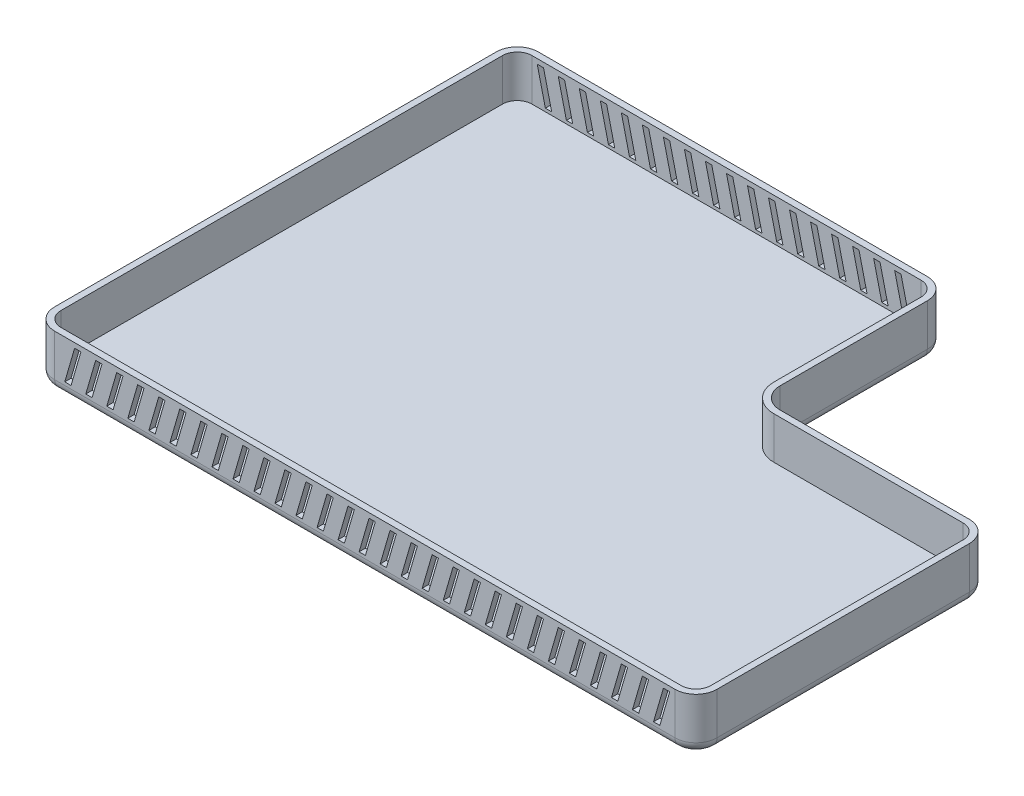
from build123d import *

# Parameters (mm, degrees)
BOSS_EXTRUDE1_DEPTH = 5
BOSS_EXTRUDE2_DEPTH = 25
FILLET1_R           = 5
CUT_EXTRUDE1_DEPTH  = 10
LPATTERN1_COUNT     = 29
LPATTERN1_PITCH     = 10
CUT_EXTRUDE2_DEPTH  = 10
LPATTERN2_COUNT     = 18
LPATTERN2_PITCH     = 10


with BuildPart() as part:
    # Sketch1 → Boss-Extrude1 (new body)
    with BuildSketch(Plane(origin=(0, 0, 0), x_dir=(1, 0, 0), z_dir=(0, 1, 0))):
        with BuildLine():
            Line((305, 140), (215, 140))
            ThreePointArc((215, 140), (207.928932188, 142.928932188), (205, 150))
            Line((205, 150), (205, 220))
            ThreePointArc((205, 220), (202.071067812, 227.071067812), (195, 230))
            Line((195, 230), (10, 230))
            ThreePointArc((10, 230), (2.928932188, 227.071067812), (0, 220))
            Line((0, 220), (0, 10))
            ThreePointArc((0, 10), (2.928932188, 2.928932188), (10, 0))
            Line((10, 0), (305, 0))
            ThreePointArc((305, 0), (312.071067812, 2.928932188), (315, 10))
            Line((315, 10), (315, 130))
            ThreePointArc((315, 130), (312.071067812, 137.071067812), (305, 140))
        make_face()
    extrude(amount=BOSS_EXTRUDE1_DEPTH)

    # Sketch3 → Boss-Extrude2 (add)
    with BuildSketch(Plane(origin=(0, 0, 0), x_dir=(1, 0, 0), z_dir=(0, 1, 0))):
        with BuildLine():
            Line((10, 0), (305, 0))
            ThreePointArc((305, 0), (312.071067812, 2.928932188), (315, 10))
            Line((315, 10), (315, 130))
            ThreePointArc((315, 130), (312.071067812, 137.071067812), (305, 140))
            Line((305, 140), (215, 140))
            ThreePointArc((215, 140), (207.928932188, 142.928932188), (205, 150))
            Line((205, 150), (205, 220))
            ThreePointArc((205, 220), (202.071067812, 227.071067812), (195, 230))
            Line((195, 230), (10, 230))
            ThreePointArc((10, 230), (2.928932188, 227.071067812), (0, 220))
            Line((0, 220), (0, 10))
            ThreePointArc((0, 10), (2.928932188, 2.928932188), (10, 0))
        make_face()
        with BuildLine():
            Line((10, 3), (305, 3))
            ThreePointArc((305, 3), (309.949747468, 5.050252532), (312, 10))
            Line((312, 10), (312, 130))
            ThreePointArc((312, 130), (309.949747468, 134.949747468), (305, 137))
            Line((305, 137), (215, 137))
            ThreePointArc((215, 137), (205.807611845, 140.807611845), (202, 150))
            Line((202, 150), (202, 220))
            ThreePointArc((202, 220), (199.949747468, 224.949747468), (195, 227))
            Line((195, 227), (10, 227))
            ThreePointArc((10, 227), (5.050252532, 224.949747468), (3, 220))
            Line((3, 220), (3, 10))
            ThreePointArc((3, 10), (5.050252532, 5.050252532), (10, 3))
        make_face(mode=Mode.SUBTRACT)
    extrude(amount=BOSS_EXTRUDE2_DEPTH)

    # Fillet1
    fillet1_edges = [part.edges().sort_by_distance(p)[0] for p in [
        (0, 0, -115),
        (2.928932188, 0, -227.071067812),
        (102.5, 0, -230),
        (202.071067812, 0, -227.071067812),
        (205, 0, -185),
        (207.928932188, 0, -142.928932188),
        (260, 0, -140),
        (312.071067812, 0, -137.071067812),
        (315, 0, -70),
        (312.071067812, 0, -2.928932188),
        (157.5, 0, 0),
        (2.928932188, 0, -2.928932188),
    ]]
    fillet(fillet1_edges, radius=FILLET1_R)

    # Sketch4 → Cut-Extrude1 (cut)
    with BuildSketch(Plane.XY):
        Polygon((297.799187642, 6.5), (294.799187642, 6.5), (299.5, 22.700711027), (302.5, 22.700711027), align=None)
    cut_extrude1 = extrude(amount=-CUT_EXTRUDE1_DEPTH, mode=Mode.SUBTRACT)

    # LPattern1: Cut-Extrude1 ×29
    with Locations(*[(-i * LPATTERN1_PITCH, 0, 0) for i in range(1, LPATTERN1_COUNT)]):
        add(cut_extrude1, mode=Mode.SUBTRACT)

    # Sketch5 → Cut-Extrude2 (cut)
    with BuildSketch(Plane(origin=(0, 0, -230), x_dir=(-1, 0, 0), z_dir=(0, 0, -1))):
        Polygon((-16.370887172, 6.5), (-19.370887172, 6.5), (-15.5, 22.700711027), (-12.5, 22.700711027), align=None)
    cut_extrude2 = extrude(amount=-CUT_EXTRUDE2_DEPTH, mode=Mode.SUBTRACT)

    # LPattern2: Cut-Extrude2 ×18
    with Locations(*[(i * LPATTERN2_PITCH, 0, 0) for i in range(1, LPATTERN2_COUNT)]):
        add(cut_extrude2, mode=Mode.SUBTRACT)


solid = part.part
